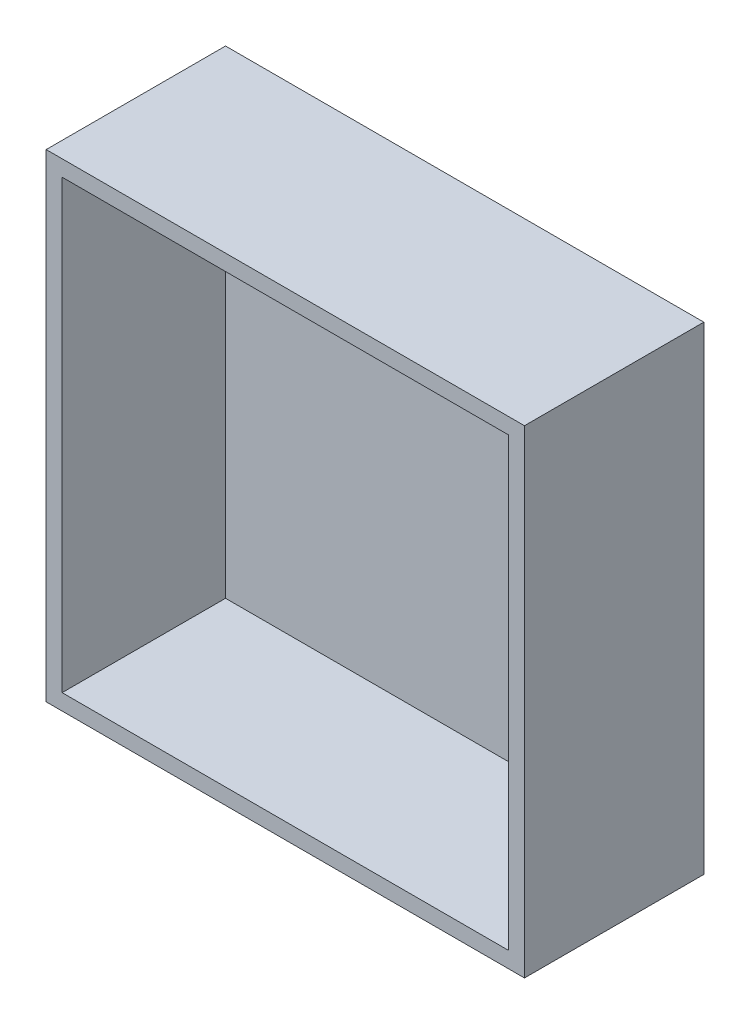
from build123d import *

# Parameters (mm, degrees)
SKETCH_1_W          = 60
SKETCH_1_H          = 60
EXTRUDE_300_DEPTH   = 22.5
SKETCH_2_W          = 56
SKETCH_2_H          = 56
CUT_EXTRUDE_1_DEPTH = 20.5
SKETCH_4_W          = 10
SKETCH_4_H          = 9
EXTRUDE_2_DEPTH     = 9
SKETCH_5_R          = 1
CUT_EXTRUDE_2_DEPTH = 8.8


with BuildPart() as part:
    # Эскиз1 → Extrude 300 (new body)
    with BuildSketch(Plane.XY):
        Rectangle(SKETCH_1_W, SKETCH_1_H)
    extrude(amount=EXTRUDE_300_DEPTH)

    # Эскиз2 → Вырез-Вытянуть1 (cut)
    with BuildSketch(Plane.XY.offset(22.5)):
        Rectangle(SKETCH_2_W, SKETCH_2_H)
    extrude(amount=-CUT_EXTRUDE_1_DEPTH, mode=Mode.SUBTRACT)

    # Эскиз4 → Бобышка-Вытянуть2 (add)
    with BuildSketch(Plane.XY.offset(2)):
        with Locations((-23, 23.5)):
            Rectangle(SKETCH_4_W, SKETCH_4_H)
    extrude(amount=EXTRUDE_2_DEPTH)

    # Эскиз5 → Вырез-Вытянуть2 (cut)
    with BuildSketch(Plane.XY.offset(11)):
        with Locations((-23, 23.5)):
            Circle(SKETCH_5_R)
    extrude(amount=-CUT_EXTRUDE_2_DEPTH, mode=Mode.SUBTRACT)


solid = part.part
